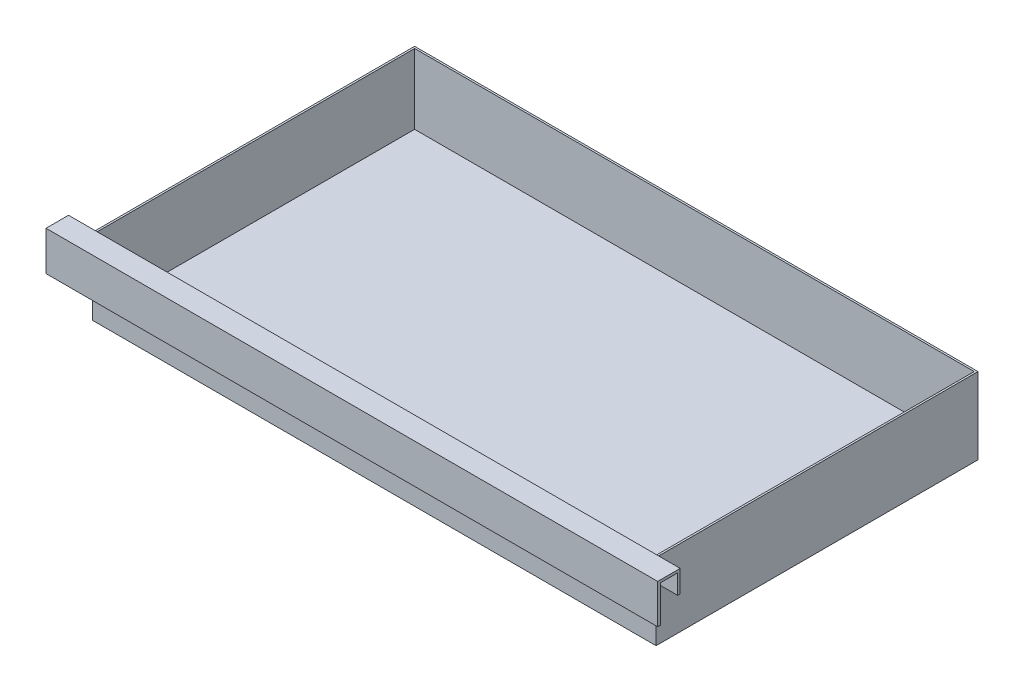
from build123d import *

# Parameters (mm, degrees)
SKETCH1_W         = 222.25
SKETCH1_H         = 127
BASE_DEPTH        = 2.54
SKETCH1_3_W       = 222.25
SKETCH1_3_H       = 127
SKETCH1_3_W_2     = 220.7514
SKETCH1_3_H_2     = 125.5014
WALLS_DEPTH       = 30.1625
HANDLE_DEPTH      = 120.65
HANDLE_DEPTH_BACK = 120.65


with BuildPart() as part:
    # Sketch1 → Base (new body)
    with BuildSketch(Plane(origin=(0, 0, 0), x_dir=(1, 0, 0), z_dir=(0, 1, 0))):
        with Locations((0, 63.5)):
            Rectangle(SKETCH1_W, SKETCH1_H)
    extrude(amount=BASE_DEPTH)

    # Sketch1_3 → Walls (add)
    with BuildSketch(Plane(origin=(0, 0, 0), x_dir=(1, 0, 0), z_dir=(0, 1, 0))):
        with Locations((0, 63.5)):
            Rectangle(SKETCH1_3_W, SKETCH1_3_H)
        with Locations((0, 63.5)):
            Rectangle(SKETCH1_3_W_2, SKETCH1_3_H_2, mode=Mode.SUBTRACT)
    extrude(amount=WALLS_DEPTH)

    # Sketch2 → Handle (add, two sides: drawn at the far end of the back side and taken through both)
    with BuildSketch(Plane(origin=(0, 0, 0), x_dir=(0, 0, -1), z_dir=(1, 0, 0)).offset(-HANDLE_DEPTH_BACK)):
        Polygon((0, 22.475414602), (0, 31.1785), (-8.89, 31.1785), (-8.89, 15.6845), (-7.874, 15.6845), (-7.874, 30.1625), (-1.016, 30.1625), (-1.016, 22.475414602), align=None)
    extrude(amount=HANDLE_DEPTH + HANDLE_DEPTH_BACK)


solid = part.part
